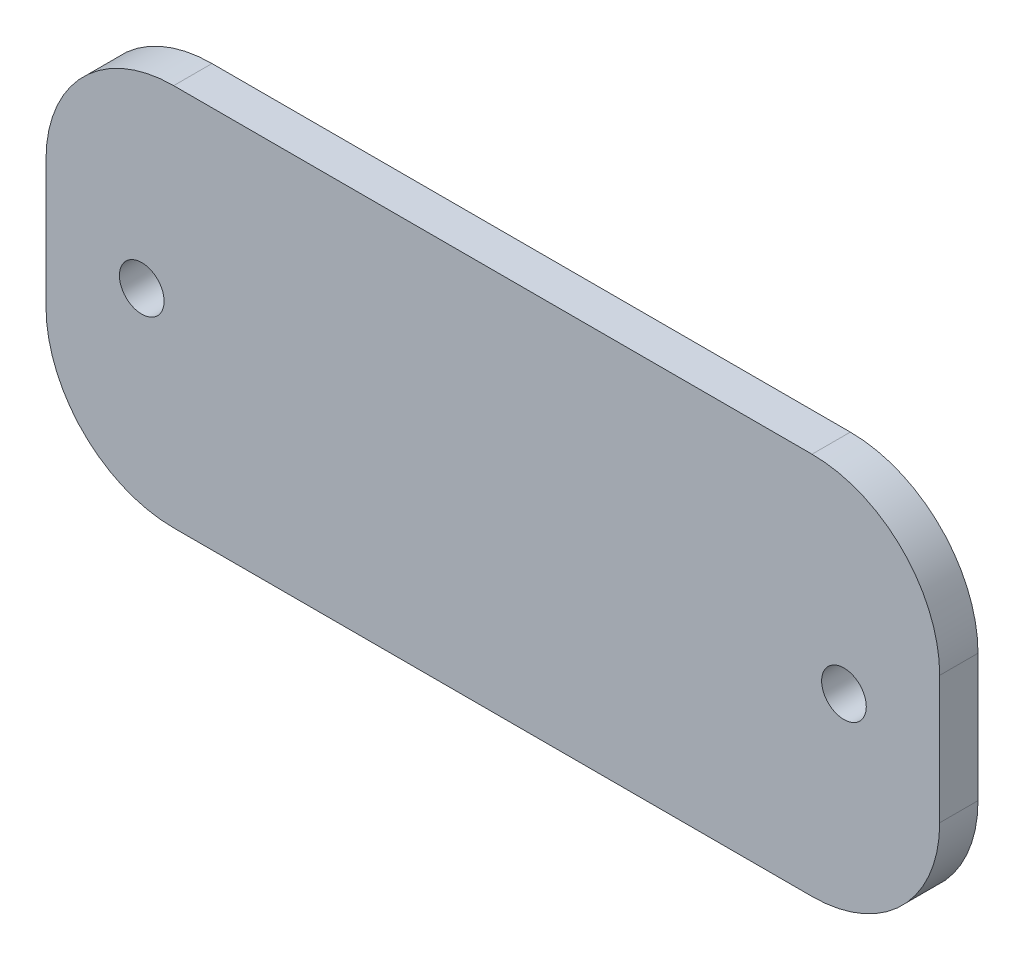
from build123d import *

# Parameters (mm, degrees)
BOSS_EXTRUDE1_DEPTH = 3
SKETCH2_R           = 1.75
CUT_EXTRUDE1_DEPTH  = 3


with BuildPart() as part:
    # Sketch1 → Boss-Extrude1 (new body)
    with BuildSketch(Plane.XY):
        with BuildLine():
            Line((-25, 15), (25, 15))
            ThreePointArc((25, 15), (32.071067812, 12.071067812), (35, 5))
            Line((35, 5), (35, -5))
            ThreePointArc((35, -5), (32.071067812, -12.071067812), (25, -15))
            Line((25, -15), (-25, -15))
            ThreePointArc((-25, -15), (-32.071067812, -12.071067812), (-35, -5))
            Line((-35, -5), (-35, 5))
            ThreePointArc((-35, 5), (-32.071067812, 12.071067812), (-25, 15))
        make_face()
    extrude(amount=BOSS_EXTRUDE1_DEPTH)

    # Sketch2 → Cut-Extrude1 (cut)
    with BuildSketch(Plane.XY.offset(3)):
        with Locations((-27.5, 0)):
            Circle(SKETCH2_R)
        with Locations((27.5, 0)):
            Circle(SKETCH2_R)
    extrude(amount=-CUT_EXTRUDE1_DEPTH, mode=Mode.SUBTRACT)


solid = part.part
